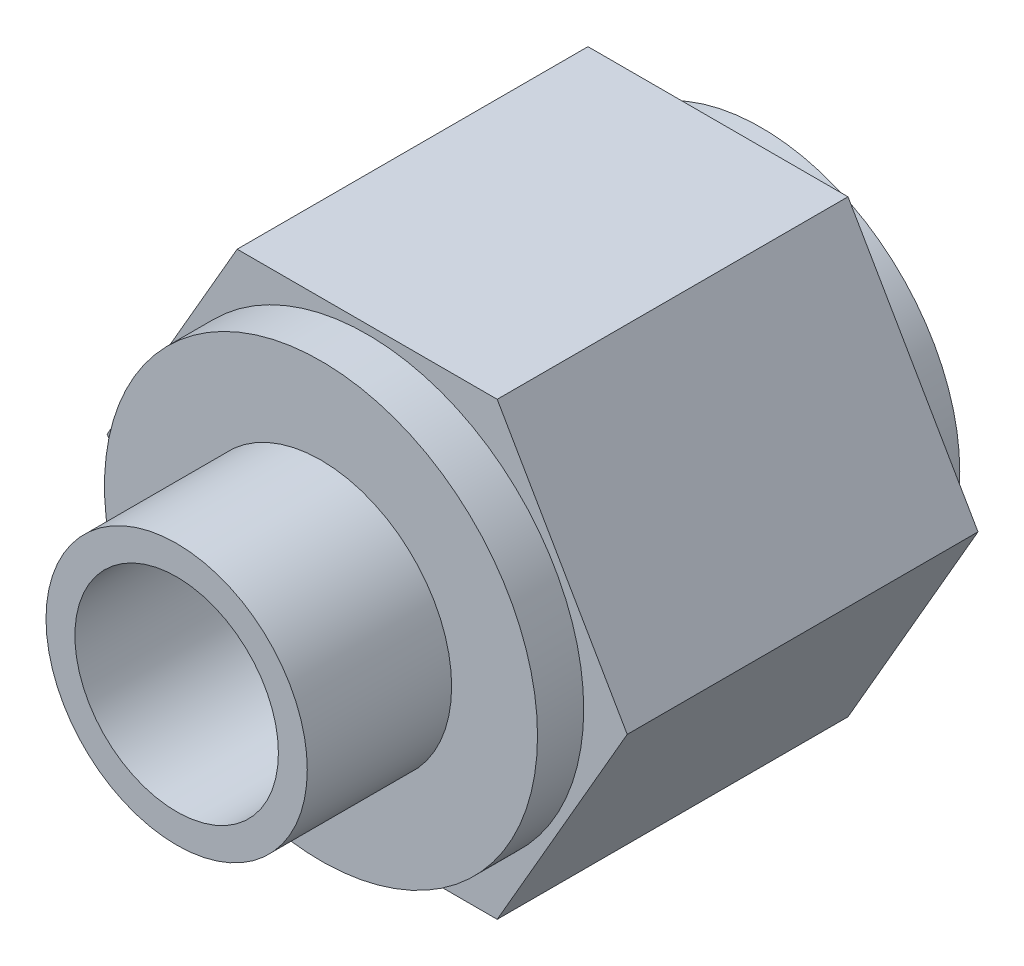
from build123d import *

# Parameters (mm, degrees)
EXTRUDE1_DEPTH     = 6.1722
SKETCH2_R          = 3.81
EXTRUDE2_DEPTH     = 0.8128
SKETCH3_R          = 2.2987
EXTRUDE3_DEPTH     = 2.54
SKETCH4_R          = 3.4925
EXTRUDE4_DEPTH     = 0.762
HOLE1_D            = 6.35
HOLE1_DEPTH        = 2.7686
SKETCH7_R          = 0.381
EXTRUDE5_DEPTH     = 2.2352
SKETCH8_R          = 1.7907
CUT_EXTRUDE1_DEPTH = 2.54


with BuildPart() as part:
    # Sketch1 → Extrude1 (new body)
    with BuildSketch(Plane.XY.offset(-3.3528)):
        Polygon((-4.575385413, 0), (-2.287692707, -3.9624), (2.287692707, -3.9624), (4.575385413, 0), (2.287692707, 3.9624), (-2.287692707, 3.9624), align=None)
    extrude(amount=-EXTRUDE1_DEPTH)

    # Sketch2 → Extrude2 (add)
    with BuildSketch(Plane.XY.offset(-3.3528)):
        Circle(SKETCH2_R)
    extrude(amount=EXTRUDE2_DEPTH)

    # Sketch3 → Extrude3 (add)
    with BuildSketch(Plane.XY.offset(-2.54)):
        Circle(SKETCH3_R)
    extrude(amount=EXTRUDE3_DEPTH)

    # Sketch4 → Extrude4 (add)
    with BuildSketch(Plane(origin=(0, 0, -9.525), x_dir=(-1, 0, 0), z_dir=(0, 0, -1))):
        Circle(SKETCH4_R)
    extrude(amount=EXTRUDE4_DEPTH)

    # Hole1
    with Locations(Plane(origin=(0, 0, -10.287), x_dir=(-1, 0, 0), z_dir=(0, 0, -1))):
        with Locations((0, 0)):
            Hole(HOLE1_D / 2, depth=HOLE1_DEPTH)

    # Sketch7 → Extrude5 (add)
    with BuildSketch(Plane(origin=(0, 0, -7.5184), x_dir=(-1, 0, 0), z_dir=(0, 0, -1))):
        Circle(SKETCH7_R)
    extrude(amount=EXTRUDE5_DEPTH)

    # Sketch8 → Cut-Extrude1 (cut)
    with BuildSketch(Plane.XY):
        Circle(SKETCH8_R)
    extrude(amount=-CUT_EXTRUDE1_DEPTH, mode=Mode.SUBTRACT)


solid = part.part
